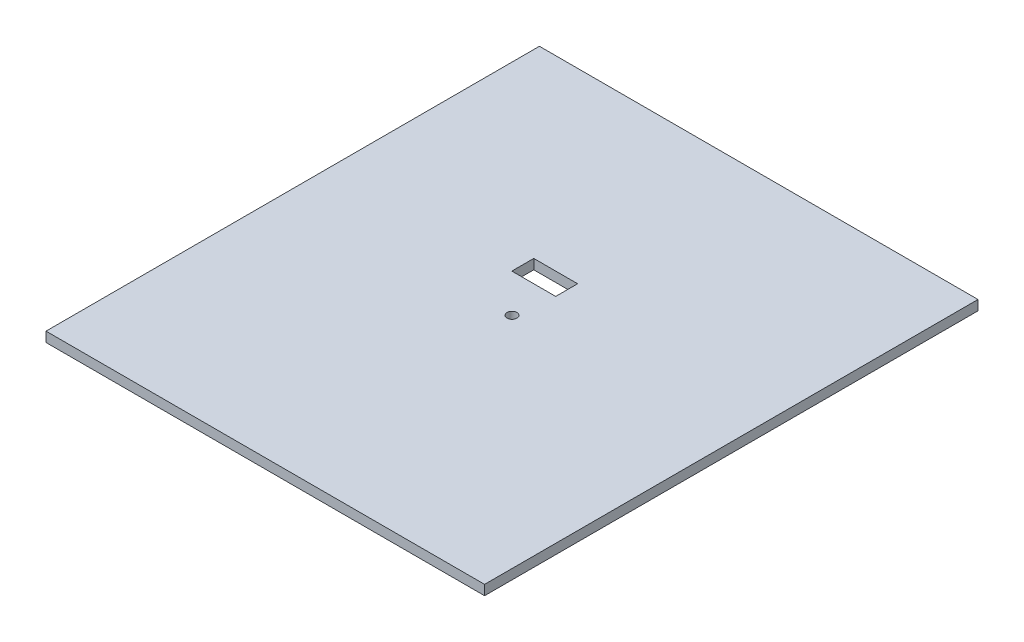
from build123d import *

# Parameters (mm, degrees)
SKETCH1_W           = 400
SKETCH1_H           = 450
BOSS_EXTRUDE5_DEPTH = 9
SKETCH4_R           = 4.5
CUT_EXTRUDE2_DEPTH  = 9
SKETCH5_W           = 40
SKETCH5_H           = 20
CUT_EXTRUDE3_DEPTH  = 9


with BuildPart() as part:
    # Sketch1 → Boss-Extrude5 (new body)
    with BuildSketch(Plane(origin=(0, 0, 0), x_dir=(1, 0, 0), z_dir=(0, 1, 0))):
        with Locations((-16.666666667, -71.794871795)):
            Rectangle(SKETCH1_W, SKETCH1_H)
    extrude(amount=BOSS_EXTRUDE5_DEPTH)

    # Sketch4 → Cut-Extrude2 (cut)
    with BuildSketch(Plane(origin=(0, 0, 0), x_dir=(1, 0, 0), z_dir=(0, 1, 0))):
        with Locations((-16.666666667, -71.794871795)):
            Circle(SKETCH4_R)
    extrude(amount=CUT_EXTRUDE2_DEPTH, mode=Mode.SUBTRACT)

    # Sketch5 → Cut-Extrude3 (cut)
    with BuildSketch(Plane(origin=(0, 0, 0), x_dir=(-1, 0, 0), z_dir=(0, -1, 0))):
        with Locations((31.666666667, -26.945924524)):
            Rectangle(SKETCH5_W, SKETCH5_H)
    extrude(amount=-CUT_EXTRUDE3_DEPTH, mode=Mode.SUBTRACT)


solid = part.part
